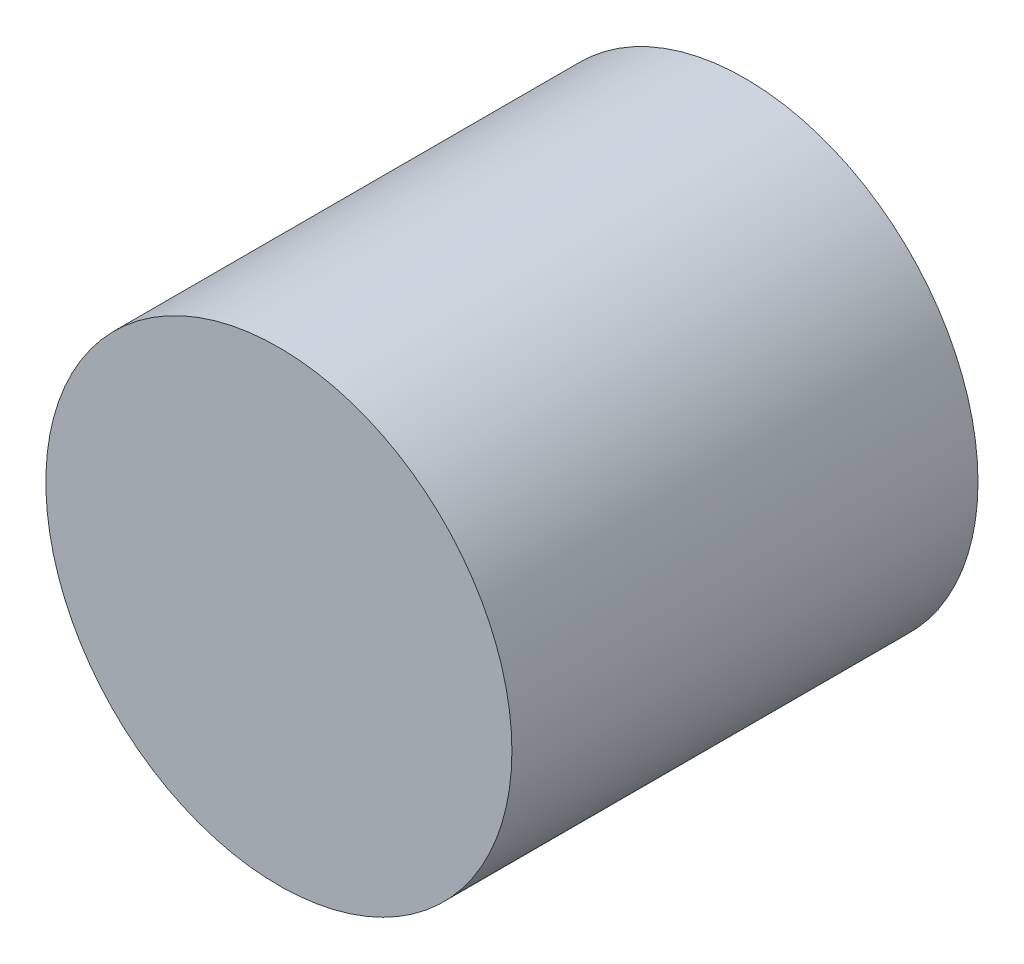
from build123d import *

# Parameters (mm, degrees)
SKETCH1_R           = 1.5
BOSS_EXTRUDE1_DEPTH = 3


with BuildPart() as part:
    # Sketch1 → Boss-Extrude1 (new body)
    with BuildSketch(Plane.XY):
        Circle(SKETCH1_R)
    extrude(amount=BOSS_EXTRUDE1_DEPTH)


solid = part.part
